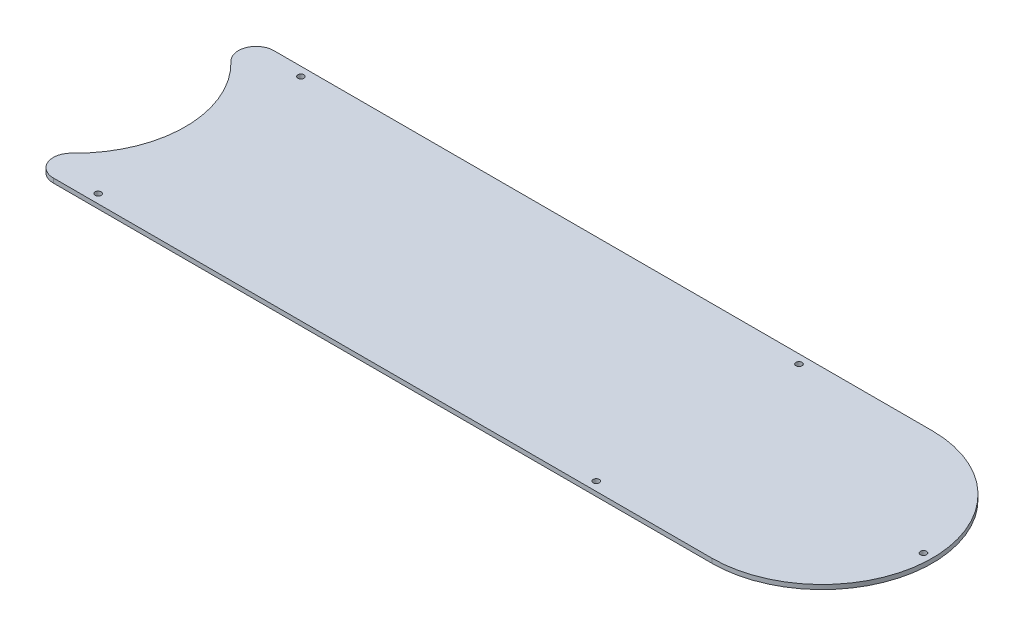
from build123d import *

# Parameters (mm, degrees)
SKETCH1_R           = 1.0922
BOSS_EXTRUDE1_DEPTH = 1.5875
FILLET1_R           = 6.35


with BuildPart() as part:
    # Sketch1 → Boss-Extrude1 (new body)
    with BuildSketch(Plane(origin=(0, 0, 0), x_dir=(1, 0, 0), z_dir=(0, 1, 0))):
        with BuildLine():
            Line((266.7, 39.37), (0, 39.37))
            ThreePointArc((0, 39.37), (39.37, 0), (0, -39.37))
            Line((0, -39.37), (266.7, -39.37))
            ThreePointArc((266.7, -39.37), (306.07, 0), (266.7, 39.37))
        make_face()
        with Locations((302.895, 0)):
            Circle(SKETCH1_R, mode=Mode.SUBTRACT)
        with Locations((222.25, 36.195)):
            Circle(SKETCH1_R, mode=Mode.SUBTRACT)
        with Locations((44.45, 36.195)):
            Circle(SKETCH1_R, mode=Mode.SUBTRACT)
        with Locations((44.45, -36.195)):
            Circle(SKETCH1_R, mode=Mode.SUBTRACT)
        with Locations((222.25, -36.195)):
            Circle(SKETCH1_R, mode=Mode.SUBTRACT)
    extrude(amount=BOSS_EXTRUDE1_DEPTH)

    # Fillet1
    fillet1_edges = [part.edges().sort_by_distance(p)[0] for p in [
        (0, 0.79375, 39.37),
        (0, 0.79375, -39.37),
    ]]
    fillet(fillet1_edges, radius=FILLET1_R)


solid = part.part
